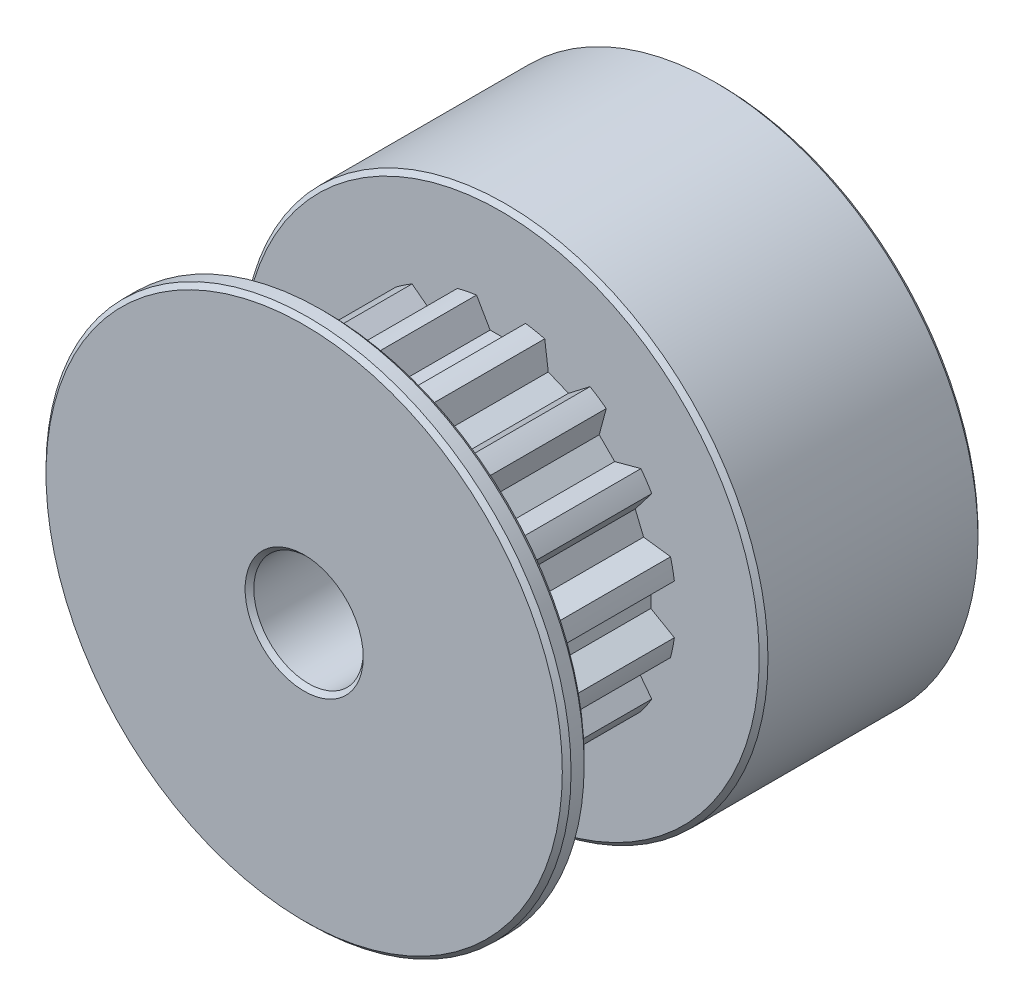
from build123d import *

# Parameters (mm, degrees)
ESQUISSE1_R                  = 8
BOSS_EXTRU_1_DEPTH           = 8
ENL_V_MAT_EXTRU_1_DEPTH      = 9
R_P_TITION_CIRCULAIRE1_COUNT = 16
ESQUISSE3_R                  = 12
BOSS_EXTRU_2_DEPTH           = 10
ESQUISSE4_R                  = 12
BOSS_EXTRU_3_DEPTH           = 1
CHANFREIN1_SIZE              = 0.2
ESQUISSE5_R                  = 2.5
ENL_V_MAT_EXTRU_2_DEPTH      = 20
CHANFREIN2_SIZE              = 0.2


with BuildPart() as part:
    # Esquisse1 → Boss.-Extru.1 (new body)
    with BuildSketch(Plane.XY):
        Circle(ESQUISSE1_R)
    extrude(amount=BOSS_EXTRU_1_DEPTH)

    # Esquisse2 → Enlèv. mat.-Extru.1 (cut, through all)
    with BuildSketch(Plane.XY.offset(8)):
        with BuildLine():
            Line((-1.120772376, 7.921102782), (-0.5, 6.845893487))
            Line((-0.5, 6.845893487), (0.5, 6.845893487))
            Line((0.5, 6.845893487), (1.120772376, 7.921102782))
            ThreePointArc((1.120772376, 7.921102782), (0, 8), (-1.120772376, 7.921102782))
        make_face()
    enl_v_mat_extru_1 = extrude(amount=-ENL_V_MAT_EXTRU_1_DEPTH, mode=Mode.SUBTRACT)

    # Répétition circulaire1: Enlèv. mat.-Extru.1 ×16 about axis
    r_p_tition_circulaire1_axis = Axis((0, 0, 0), (0, 0, 1))
    for i in range(1, R_P_TITION_CIRCULAIRE1_COUNT):
        add(enl_v_mat_extru_1.rotate(r_p_tition_circulaire1_axis, i * 360 / R_P_TITION_CIRCULAIRE1_COUNT), mode=Mode.SUBTRACT)

    # Esquisse3 → Boss.-Extru.2 (add)
    with BuildSketch(Plane(origin=(0, 0, 0), x_dir=(-1, 0, 0), z_dir=(0, 0, -1))):
        Circle(ESQUISSE3_R)
    extrude(amount=BOSS_EXTRU_2_DEPTH)

    # Esquisse4 → Boss.-Extru.3 (add)
    with BuildSketch(Plane.XY.offset(8)):
        Circle(ESQUISSE4_R)
    extrude(amount=BOSS_EXTRU_3_DEPTH)

    # Chanfrein1
    chanfrein1_edges = [part.edges().sort_by_distance(p)[0] for p in [
        (12, 0, 0),
        (12, 0, -10),
        (-12, 0, 8),
        (-12, 0, 9),
    ]]
    chamfer(chanfrein1_edges, length=CHANFREIN1_SIZE)

    # Esquisse5 → Enlèv. mat.-Extru.2 (cut, through all)
    with BuildSketch(Plane(origin=(0, 0, -10), x_dir=(-1, 0, 0), z_dir=(0, 0, -1))):
        Circle(ESQUISSE5_R)
    extrude(amount=-ENL_V_MAT_EXTRU_2_DEPTH, mode=Mode.SUBTRACT)

    # Chanfrein2
    chanfrein2_edges = [part.edges().sort_by_distance(p)[0] for p in [
        (2.5, 0, 9),
        (2.5, 0, -10),
    ]]
    chamfer(chanfrein2_edges, length=CHANFREIN2_SIZE)


solid = part.part
